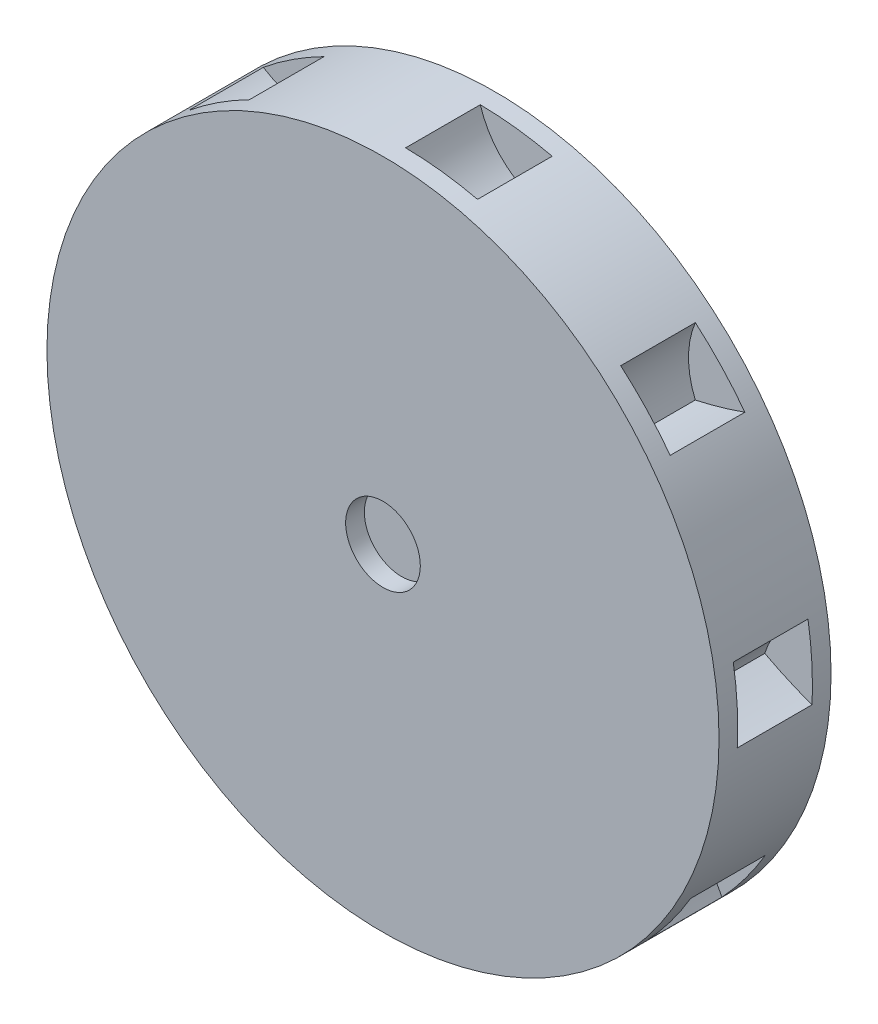
from build123d import *

# Parameters (mm, degrees)
SKETCH1_R           = 45
SKETCH1_R_2         = 5
BOSS_EXTRUDE1_DEPTH = 2.5
BOSS_EXTRUDE2_DEPTH = 10
CIRPATTERN3_COUNT   = 9
BOSS_EXTRUDE6_DEPTH = 10
CIRPATTERN4_COUNT   = 9


with BuildPart() as part:
    # Sketch1 → Boss-Extrude1 (new body)
    with BuildSketch(Plane.XY):
        Circle(SKETCH1_R)
        Circle(SKETCH1_R_2, mode=Mode.SUBTRACT)
    boss_extrude1 = extrude(amount=BOSS_EXTRUDE1_DEPTH)

    # Sketch2 → Boss-Extrude2 (add)
    with BuildSketch(Plane(origin=(0, 0, 0), x_dir=(-1, 0, 0), z_dir=(0, 0, -1))):
        with BuildLine():
            Line((2.376945651, 27.919273565), (2.996801322, 28.703989404))
            ThreePointArc((2.996801322, 28.703989404), (-1.593989447, 32.774038165), (-5.693957299, 37.338128482))
            ThreePointArc((-5.693957299, 37.338128482), (-1.825718804, 40.535941838), (0.472898867, 44.997515117))
            ThreePointArc((0.472898867, 44.997515117), (-0.028187178, 44.999991172), (-0.529269728, 44.996887376))
            ThreePointArc((-0.529269728, 44.996887376), (-2.71555077, 40.967370456), (-6.298348731, 38.107232317))
            ThreePointArc((-6.298348731, 38.107232317), (-8.321118794, 40.910790025), (-10.160523263, 43.837926126))
            ThreePointArc((-10.160523263, 43.837926126), (-10.667701719, 43.717275076), (-11.173448403, 43.590756483))
            ThreePointArc((-11.173448403, 43.590756483), (-5.142118978, 35.111827702), (2.376945651, 27.919273565))
        make_face()
    boss_extrude2 = extrude(amount=BOSS_EXTRUDE2_DEPTH)

    # CirPattern3: Boss-Extrude2 ×9 about axis
    cirpattern3_axis = Axis((0, 0, 0), (0, 0, 1))
    for i in range(1, CIRPATTERN3_COUNT):
        add(boss_extrude2.rotate(cirpattern3_axis, i * 360 / CIRPATTERN3_COUNT))

    # Sketch3 → Boss-Extrude6 (add)
    with BuildSketch(Plane(origin=(0, 0, 0), x_dir=(-1, 0, 0), z_dir=(0, 0, -1))):
        with BuildLine():
            ThreePointArc((0.145366303, 43.995082638), (9.96868345, 42.851065074), (19.288277599, 39.541759887))
            ThreePointArc((19.288277599, 39.541759887), (19.371803139, 40.058594285), (19.460240105, 40.574610966))
            ThreePointArc((19.460240105, 40.574610966), (10.208967999, 43.826669648), (0.472898867, 44.997515117))
            ThreePointArc((0.472898867, 44.997515117), (0.31970879, 44.492843232), (0.145366303, 43.995082638))
        make_face()
    boss_extrude6 = extrude(amount=BOSS_EXTRUDE6_DEPTH)

    # CirPattern4: Boss-Extrude6 ×9 about axis
    cirpattern4_axis = Axis((0, 0, 2.5), (0, 0, -1))
    for i in range(1, CIRPATTERN4_COUNT):
        add(boss_extrude6.rotate(cirpattern4_axis, i * 360 / CIRPATTERN4_COUNT))

    # Mirror3: Boss-Extrude1 across plane
    add(boss_extrude1.mirror(Plane.XY.offset(-5)))


solid = part.part
